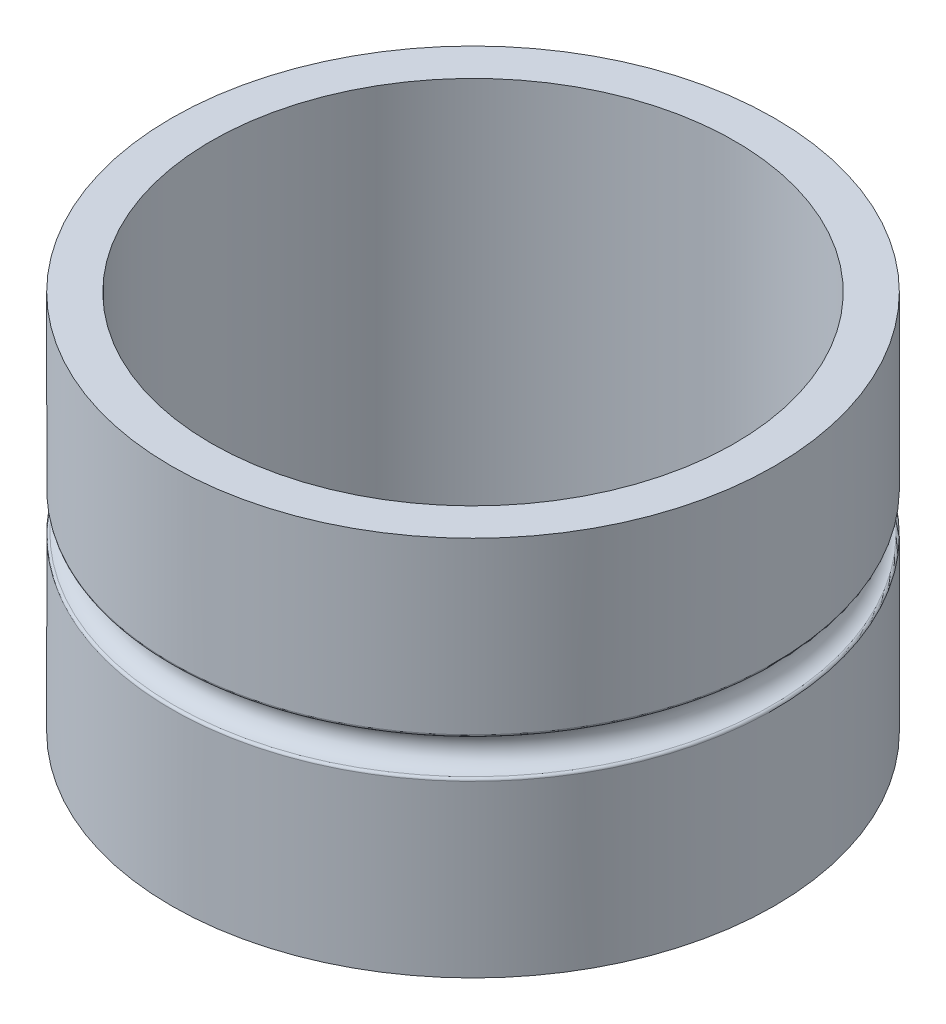
from build123d import *

# Parameters (mm, degrees)
SKETCH1_R           = 60.325
SKETCH1_R_2         = 52.3875
BOSS_EXTRUDE1_DEPTH = 76.2
FILLET1_R           = 0.508


with BuildPart() as part:
    # Sketch1 → Boss-Extrude1 (new body)
    with BuildSketch(Plane(origin=(0, 0, 0), x_dir=(1, 0, 0), z_dir=(0, 1, 0))):
        Circle(SKETCH1_R)
        Circle(SKETCH1_R_2, mode=Mode.SUBTRACT)
    extrude(amount=BOSS_EXTRUDE1_DEPTH)

    # Sketch2 → Cut-Revolve1 (revolve, cut)
    with BuildSketch(Plane.XY):
        with BuildLine():
            ThreePointArc((60.325, 41.656), (56.769, 38.1), (60.325, 34.544))
            Line((60.325, 34.544), (60.325, 41.656))
        make_face()
    revolve(axis=Axis((0, 76.2, 0), (0, -1, 0)), mode=Mode.SUBTRACT)

    # Fillet1
    fillet1_edges = [part.edges().sort_by_distance(p)[0] for p in [
        (-60.325, 34.544, 0),
        (-60.325, 41.656, 0),
    ]]
    fillet(fillet1_edges, radius=FILLET1_R)


solid = part.part
